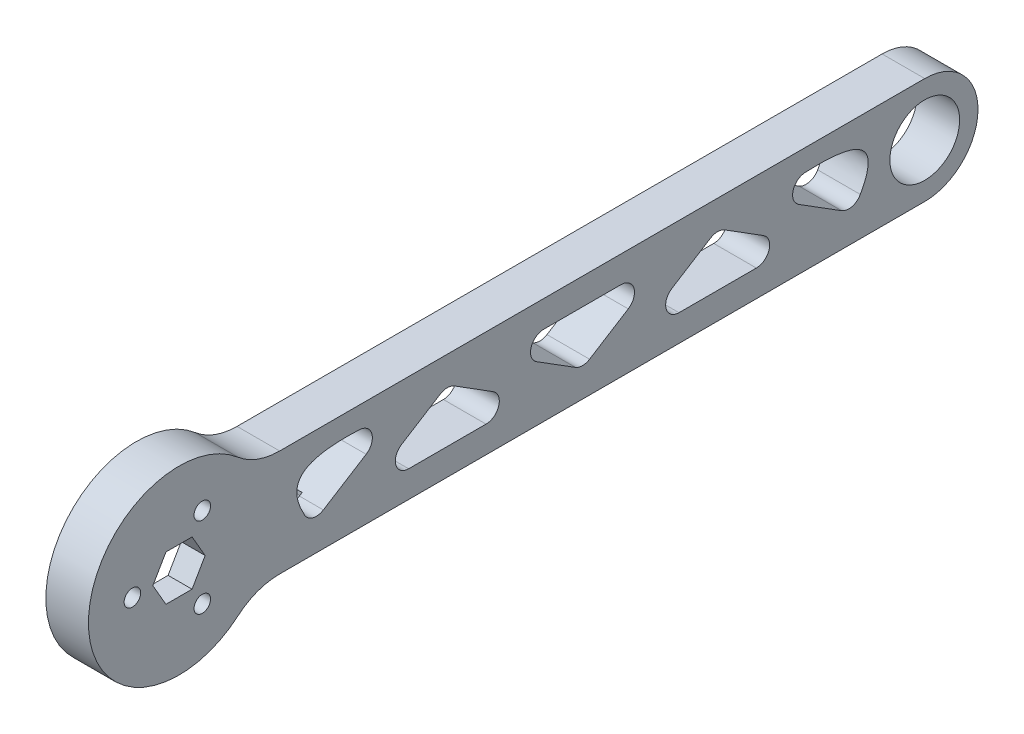
from build123d import *

# Parameters (mm, degrees)
SKETCH_1_R          = 6.55
EXTRUDE_1_DEPTH     = 8
CUT_EXTRUDE_1_DEPTH = 3.5
SKETCH_3_R          = 1.55
CUT_EXTRUDE_2_DEPTH = 5.5000001


with BuildPart() as part:
    # 草图1 → 凸台-拉伸1 (new body)
    with BuildSketch(Plane(origin=(-4, 0, 0), x_dir=(0, -1, 0), z_dir=(-1, 0, 0))):
        with BuildLine():
            Line((-10, -18.894443628), (-10, -140))
            ThreePointArc((-10, -140), (0, -150), (10, -140))
            Line((10, -140), (10, -18.894443628))
            ThreePointArc((10, -18.894443628), (10.74741409, -14.725593625), (12.896551724, -11.076053161))
            ThreePointArc((12.896551724, -11.076053161), (0, 17), (-12.896551724, -11.076053161))
            ThreePointArc((-12.896551724, -11.076053161), (-10.74741409, -14.725593625), (-10, -18.894443628))
        make_face()
        with Locations((0, -140)):
            Circle(SKETCH_1_R, mode=Mode.SUBTRACT)
        with BuildLine():
            Line((-4.168179012, -99.797532142), (0.381550311, -92.536811957))
            ThreePointArc((0.381550311, -92.536811957), (3.190606899, -91.461560083), (5, -93.864279815))
            Line((5, -93.864279815), (5, -108.385720185))
            ThreePointArc((5, -108.385720185), (3.190606899, -110.788439917), (0.381550311, -109.713188043))
            Line((0.381550311, -109.713188043), (-4.168179012, -102.452467858))
            ThreePointArc((-4.168179012, -102.452467858), (-4.549729323, -101.125), (-4.168179012, -99.797532142))
        make_face(mode=Mode.SUBTRACT)
        with BuildLine():
            Line((-1.347932676, -116.369603301), (3.683273316, -124.398691695))
            ThreePointArc((3.683273316, -124.398691695), (3.98786354, -126.341689874), (2.792876182, -127.903746961))
            add(Edge.make_bspline(
                [(2.792876182, -127.903746961), (-2.877603269, -131.101619406), (-5.985402229, -127.808170374), (-6.076762251, -119.793304589), (-5.963124704, -117.569487096)],
                knots=[0.005408839, 0.005408839, 0.005408839, 0.005408839, 0.693539789, 0.980498212, 0.980498212, 0.980498212, 0.980498212], degree=3))
            ThreePointArc((-5.963124704, -117.569487096), (-4.09543452, -115.277506448), (-1.347932676, -116.369603301))
        make_face(mode=Mode.SUBTRACT)
        with BuildLine():
            Line((0.381550311, -58.963188043), (-4.168179012, -51.702467858))
            ThreePointArc((-4.168179012, -51.702467858), (-4.549729323, -50.375), (-4.168179012, -49.047532142))
            Line((-4.168179012, -49.047532142), (0.381550311, -41.786811957))
            ThreePointArc((0.381550311, -41.786811957), (3.190606899, -40.711560083), (5, -43.114279815))
            Line((5, -43.114279815), (5, -57.635720185))
            ThreePointArc((5, -57.635720185), (3.190606899, -60.038439917), (0.381550311, -58.963188043))
        make_face(mode=Mode.SUBTRACT)
        with BuildLine():
            Line((3.683273317, -27.101308304), (-1.347932676, -35.130396699))
            ThreePointArc((-1.347932676, -35.130396699), (-4.095434519, -36.222493552), (-5.963124704, -33.930512906))
            add(Edge.make_bspline(
                [(-5.963124704, -33.930512906), (-6.076762251, -31.706695412), (-5.98540223, -23.691829624), (-2.877603269, -20.398380591), (2.792876182, -23.596253037)],
                knots=[0.005408839, 0.005408839, 0.005408839, 0.005408839, 0.292367263, 0.980498213, 0.980498213, 0.980498213, 0.980498213], degree=3))
            ThreePointArc((2.792876182, -23.596253037), (3.987863541, -25.158310124), (3.683273317, -27.101308304))
        make_face(mode=Mode.SUBTRACT)
        with BuildLine():
            Line((4.168179012, -77.077467858), (-0.381550311, -84.338188043))
            ThreePointArc((-0.381550311, -84.338188043), (-3.190606899, -85.413439917), (-5, -83.010720185))
            Line((-5, -83.010720185), (-5, -68.489279815))
            ThreePointArc((-5, -68.489279815), (-3.190606899, -66.086560083), (-0.381550311, -67.161811957))
            Line((-0.381550311, -67.161811957), (4.168179012, -74.422532142))
            ThreePointArc((4.168179012, -74.422532142), (4.549729323, -75.75), (4.168179012, -77.077467858))
        make_face(mode=Mode.SUBTRACT)
    extrude(amount=-EXTRUDE_1_DEPTH)

    # 草图2 → 切除-拉伸1 (cut)
    with BuildSketch(Plane.ZY.offset(4)):
        with BuildLine():
            Line((-23.794604197, 5), (-27.625420737, 5))
            Line((-27.625420737, 5), (-27.625420737, -4.039591784))
            ThreePointArc((-27.625420737, -4.039591784), (-27.344123683, -4.718702946), (-26.665012521, -5))
            Line((-26.665012521, -5), (-23.794604197, -5))
            Line((-23.794604197, -5), (-10.507616285, -5))
            ThreePointArc((-10.507616285, -5), (-10.005554421, -5.135168291), (-9.639218245, -5.504132231))
            ThreePointArc((-9.639218245, -5.504132231), (11.1, 0), (-9.639218245, 5.504132231))
            ThreePointArc((-9.639218245, 5.504132231), (-10.005554421, 5.135168291), (-10.507616285, 5))
            Line((-10.507616285, 5), (-23.794604197, 5))
        make_face()
    extrude(amount=-CUT_EXTRUDE_1_DEPTH, mode=Mode.SUBTRACT)

    # 草图3 → 切除-拉伸2 (cut, through all)
    with BuildSketch(Plane.ZY.offset(0.5)):
        with Locations((-4.375, 7.577722283)):
            Circle(SKETCH_3_R)
        with Locations((-4.375, -7.577722283)):
            Circle(SKETCH_3_R)
        with Locations((8.75, 0)):
            Circle(SKETCH_3_R)
        Polygon((4.907477288, 0), (2.453738644, 4.25), (-2.453738644, 4.25), (-4.907477288, 0), (-2.453738644, -4.25), (2.453738644, -4.25), align=None)
    extrude(amount=-CUT_EXTRUDE_2_DEPTH, mode=Mode.SUBTRACT)


solid = part.part
